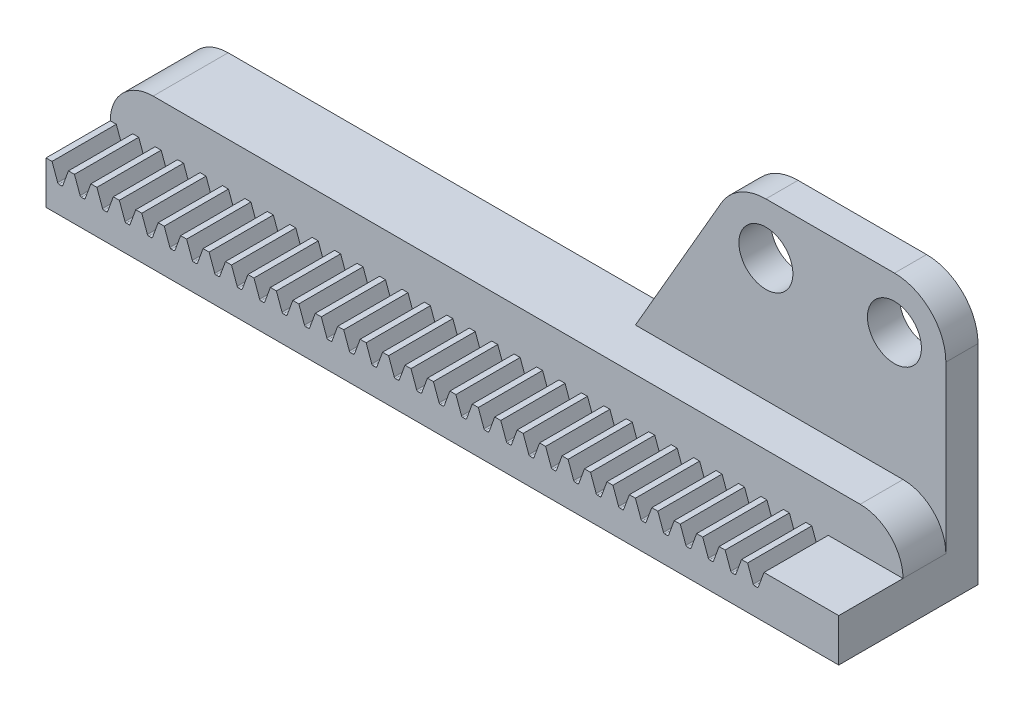
from build123d import *

# Parameters (mm, degrees)
SKETCH3_W                = 4.7625
SKETCH3_H                = 3.175
BOSS_EXTRUDE1_DEPTH      = 29.36875
BOSS_EXTRUDE1_DEPTH_BACK = 29.36875
CUT_EXTRUDE1_DEPTH       = 3.38125
FILLET1_R                = 0.099598028
LPATTERN1_COUNT          = 32
LPATTERN1_PITCH          = 1.66243
FILLET1_OF_LPATTERN1_R   = 0.099598028
BOSS_EXTRUDE2_DEPTH      = 5.55625
SKETCH9_R                = 2
BOSS_EXTRUDE3_DEPTH      = 2.38125


with BuildPart() as part:
    # Sketch3 → Boss-Extrude1 (new body, two sides)
    with BuildSketch(Plane(origin=(0, 0, 0), x_dir=(0, 0, -1), z_dir=(1, 0, 0))) as boss_extrude1_sk:
        Rectangle(SKETCH3_W, SKETCH3_H)
    extrude(amount=BOSS_EXTRUDE1_DEPTH)
    extrude(boss_extrude1_sk.sketch, amount=-BOSS_EXTRUDE1_DEPTH_BACK)

    # Sketch4 → Cut-Extrude1 (cut, symmetric)
    with BuildSketch(Plane.XY):
        Polygon((-28.922736831, 1.5875), (-28.480525129, 0.372533333), (-28.148531702, 0.372533333), (-27.70632, 1.5875), align=None)
    cut_extrude1 = extrude(amount=CUT_EXTRUDE1_DEPTH, both=True, mode=Mode.SUBTRACT)

    # Fillet1
    fillet1_edges = [part.edges().sort_by_distance(p)[0] for p in [
        (-28.148531702, 0.372533333, 0),
        (-28.480525129, 0.372533333, 0),
    ]]
    fillet(fillet1_edges, radius=FILLET1_R)

    # LPattern1: Cut-Extrude1 ×32
    with Locations(*[(i * LPATTERN1_PITCH, 0, 0) for i in range(1, LPATTERN1_COUNT)]):
        add(cut_extrude1, mode=Mode.SUBTRACT)

    # Fillet1 of LPattern1
    fillet1_of_lpattern1_edges = [part.edges().sort_by_distance(p)[0] for p in [
        (-26.486101702, 0.372533333, 0),
        (-26.818095129, 0.372533333, 0),
        (-24.823671702, 0.372533333, 0),
        (-25.155665129, 0.372533333, 0),
        (-23.161241702, 0.372533333, 0),
        (-23.493235129, 0.372533333, 0),
        (-21.498811702, 0.372533333, 0),
        (-21.830805129, 0.372533333, 0),
        (-19.836381702, 0.372533333, 0),
        (-20.168375129, 0.372533333, 0),
        (-18.173951702, 0.372533333, 0),
        (-18.505945129, 0.372533333, 0),
        (-16.511521702, 0.372533333, 0),
        (-16.843515129, 0.372533333, 0),
        (-14.849091702, 0.372533333, 0),
        (-15.181085129, 0.372533333, 0),
        (-13.186661702, 0.372533333, 0),
        (-13.518655129, 0.372533333, 0),
        (-11.524231702, 0.372533333, 0),
        (-11.856225129, 0.372533333, 0),
        (-9.861801702, 0.372533333, 0),
        (-10.193795129, 0.372533333, 0),
        (-8.199371702, 0.372533333, 0),
        (-8.531365129, 0.372533333, 0),
        (-6.536941702, 0.372533333, 0),
        (-6.868935129, 0.372533333, 0),
        (-4.874511702, 0.372533333, 0),
        (-5.206505129, 0.372533333, 0),
        (-3.212081702, 0.372533333, 0),
        (-3.544075129, 0.372533333, 0),
        (-1.549651702, 0.372533333, 0),
        (-1.881645129, 0.372533333, 0),
        (0.112778298, 0.372533333, 0),
        (-0.219215129, 0.372533333, 0),
        (1.775208298, 0.372533333, 0),
        (1.443214871, 0.372533333, 0),
        (3.437638298, 0.372533333, 0),
        (3.105644871, 0.372533333, 0),
        (5.100068298, 0.372533333, 0),
        (4.768074871, 0.372533333, 0),
        (6.762498298, 0.372533333, 0),
        (6.430504871, 0.372533333, 0),
        (8.424928298, 0.372533333, 0),
        (8.092934871, 0.372533333, 0),
        (10.087358298, 0.372533333, 0),
        (9.755364871, 0.372533333, 0),
        (11.749788298, 0.372533333, 0),
        (11.417794871, 0.372533333, 0),
        (13.412218298, 0.372533333, 0),
        (13.080224871, 0.372533333, 0),
        (15.074648298, 0.372533333, 0),
        (14.742654871, 0.372533333, 0),
        (16.737078298, 0.372533333, 0),
        (16.405084871, 0.372533333, 0),
        (18.399508298, 0.372533333, 0),
        (18.067514871, 0.372533333, 0),
        (20.061938298, 0.372533333, 0),
        (19.729944871, 0.372533333, 0),
        (21.724368298, 0.372533333, 0),
        (21.392374871, 0.372533333, 0),
        (23.386798298, 0.372533333, 0),
        (23.054804871, 0.372533333, 0),
    ]]
    fillet(fillet1_of_lpattern1_edges, radius=FILLET1_OF_LPATTERN1_R)

    # Sketch8 → Boss-Extrude2 (add)
    with BuildSketch(Plane(origin=(0, 0, -2.38125), x_dir=(-1, 0, 0), z_dir=(0, 0, -1))):
        with BuildLine():
            Line((-29.36875, -1.5875), (-29.36875, 1.5875))
            ThreePointArc((-29.36875, 1.5875), (-28.43881403, 3.83256403), (-26.19375, 4.7625))
            Line((-26.19375, 4.7625), (26.19375, 4.7625))
            ThreePointArc((26.19375, 4.7625), (28.43881403, 3.83256403), (29.36875, 1.5875))
            Line((29.36875, 1.5875), (29.36875, -1.5875))
            Line((29.36875, -1.5875), (-29.36875, -1.5875))
        make_face()
    extrude(amount=BOSS_EXTRUDE2_DEPTH)

    # Sketch9 → Boss-Extrude3 (add)
    with BuildSketch(Plane.XY.offset(-7.9375)):
        with BuildLine():
            Line((29.36875, -1.5875), (2.703540575, -1.5875))
            Line((2.703540575, -1.5875), (12.734193212, 15.7861))
            ThreePointArc((12.734193212, 15.7861), (14.12875, 17.180656788), (16.03375, 17.6911))
            Line((16.03375, 17.6911), (25.55875, 17.6911))
            ThreePointArc((25.55875, 17.6911), (28.252826836, 16.575176836), (29.36875, 13.8811))
            Line((29.36875, 13.8811), (29.36875, -1.5875))
        make_face()
        with Locations((16.03375, 13.8811)):
            Circle(SKETCH9_R, mode=Mode.SUBTRACT)
        with Locations((25.55875, 13.8811)):
            Circle(SKETCH9_R, mode=Mode.SUBTRACT)
    extrude(amount=BOSS_EXTRUDE3_DEPTH)


solid = part.part
